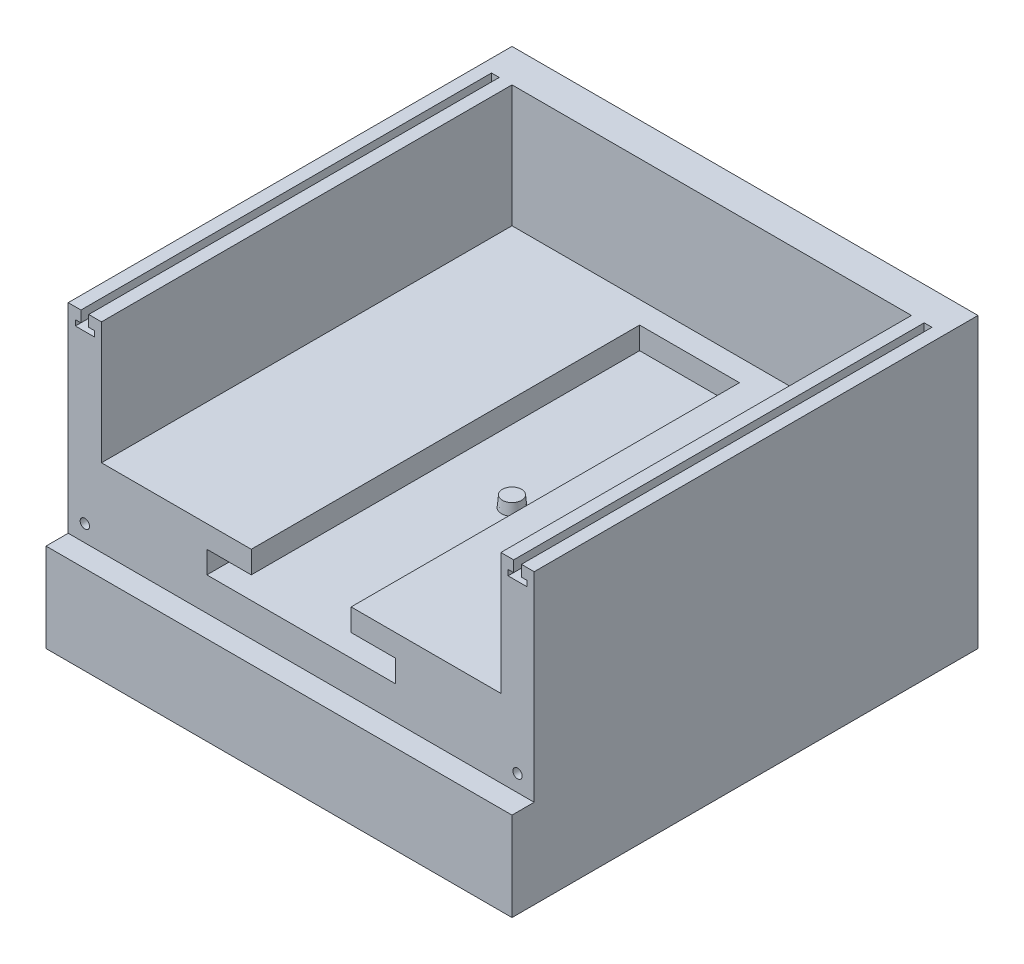
from build123d import *

# Parameters (mm, degrees)
BOSS_EXTRUDE1_DEPTH = 225
BOSS_EXTRUDE2_DEPTH = 10
SKETCH6_W           = 210
SKETCH6_H           = 200
BOSS_EXTRUDE3_DEPTH = 15
SKETCH5_R           = 2.1
CUT_EXTRUDE1_DEPTH  = 6
SKETCH10_W          = 210
SKETCH10_H          = 200
BOSS_EXTRUDE4_DEPTH = 40
SKETCH11_R          = 4.75
BOSS_EXTRUDE5_DEPTH = 5
BOSS_EXTRUDE5_TAPER = 5
SKETCH13_W          = 185
SKETCH13_H          = 10
BOSS_EXTRUDE6_DEPTH = 47.5
SKETCH14_W          = 185
SKETCH14_H          = 10
BOSS_EXTRUDE7_DEPTH = 47.5
SKETCH7_W           = 21
SKETCH7_H           = 10.25
CUT_EXTRUDE2_DEPTH  = 15
SKETCH15_R          = 2.1
CUT_EXTRUDE4_DEPTH  = 4.5
CUT_EXTRUDE5_DEPTH  = 185
SKETCH17_W          = 210
SKETCH17_H          = 40
BOSS_EXTRUDE8_DEPTH = 10


with BuildPart() as part:
    # Sketch2 → Boss-Extrude1 (new body)
    with BuildSketch(Plane(origin=(0, 0, 0), x_dir=(1, 0, 0), z_dir=(0, 1, 0))):
        Polygon((-90, 0), (90, 0), (90, -185), (105, -185), (105, 15), (-105, 15), (-105, -185), (-90, -185), align=None)
    extrude(amount=BOSS_EXTRUDE1_DEPTH)

    # Sketch3 → Boss-Extrude2 (add)
    with BuildSketch(Plane(origin=(0, 10, 0), x_dir=(1, 0, 0), z_dir=(0, 1, 0))):
        Polygon((-90, -185), (-22.5, -185), (-22.5, -10), (22.5, -10), (22.5, -185), (90, -185), (90, 0), (-90, 0), align=None)
    extrude(amount=BOSS_EXTRUDE2_DEPTH)

    # Sketch6 → Boss-Extrude3 (add)
    with BuildSketch(Plane.XZ):
        with Locations((0, 85)):
            Rectangle(SKETCH6_W, SKETCH6_H)
    extrude(amount=BOSS_EXTRUDE3_DEPTH)

    # Sketch5 → Cut-Extrude1 (cut)
    with BuildSketch(Plane.XY.offset(185)):
        with Locations((-97.5, 217.5)):
            Circle(SKETCH5_R)
        with Locations((97.5, 217.5)):
            Circle(SKETCH5_R)
        with Locations((-97.5, -7.5)):
            Circle(SKETCH5_R)
        with Locations((97.5, -7.5)):
            Circle(SKETCH5_R)
    extrude(amount=-CUT_EXTRUDE1_DEPTH, mode=Mode.SUBTRACT)

    # Sketch10 → Boss-Extrude4 (add)
    with BuildSketch(Plane.XZ.offset(15)):
        with Locations((0, 85)):
            Rectangle(SKETCH10_W, SKETCH10_H)
    extrude(amount=BOSS_EXTRUDE4_DEPTH)

    # Sketch11 → Boss-Extrude5 (add)
    with BuildSketch(Plane(origin=(0, 0, 0), x_dir=(1, 0, 0), z_dir=(0, 1, 0))):
        with Locations((0, -90)):
            Circle(SKETCH11_R)
    extrude(amount=BOSS_EXTRUDE5_DEPTH, taper=BOSS_EXTRUDE5_TAPER)

    # Sketch13 → Boss-Extrude6 (add)
    with BuildSketch(Plane.ZY.offset(-90)):
        with Locations((92.5, 5)):
            Rectangle(SKETCH13_W, SKETCH13_H)
    extrude(amount=BOSS_EXTRUDE6_DEPTH)

    # Sketch14 → Boss-Extrude7 (add)
    with BuildSketch(Plane(origin=(-90, 0, 0), x_dir=(0, 0, -1), z_dir=(1, 0, 0))):
        with Locations((-92.5, 5)):
            Rectangle(SKETCH14_W, SKETCH14_H)
    extrude(amount=BOSS_EXTRUDE7_DEPTH)

    # Sketch7 → Cut-Extrude2 (cut)
    with BuildSketch(Plane(origin=(0, 0, -15), x_dir=(-1, 0, 0), z_dir=(0, 0, -1))):
        with Locations((-32, 5.125)):
            Rectangle(SKETCH7_W, SKETCH7_H)
    extrude(amount=-CUT_EXTRUDE2_DEPTH, mode=Mode.SUBTRACT)

    # Sketch15 → Cut-Extrude4 (cut)
    with BuildSketch(Plane(origin=(0, 225, 0), x_dir=(1, 0, 0), z_dir=(0, 1, 0))):
        with Locations((0, 7.5)):
            Circle(SKETCH15_R)
        with Locations((-97.5, -90)):
            Circle(SKETCH15_R)
        with Locations((97.5, -90)):
            Circle(SKETCH15_R)
    extrude(amount=-CUT_EXTRUDE4_DEPTH, mode=Mode.SUBTRACT)

    # Split1
    split(bisect_by=Plane.ZX.offset(75), keep=Keep.BOTTOM)

    # Sketch16 → Cut-Extrude5 (cut)
    with BuildSketch(Plane.XY.offset(185)):
        Polygon((-99.25, 75), (-99.25, 70), (-101.75, 70), (-101.75, 67.5), (-93.25, 67.5), (-93.25, 70), (-95.75, 70), (-95.75, 75), align=None)
        Polygon((95.75, 70), (95.75, 75), (99.25, 75), (99.25, 70), (101.75, 70), (101.75, 67.5), (93.25, 67.5), (93.25, 70), align=None)
    extrude(amount=-CUT_EXTRUDE5_DEPTH, mode=Mode.SUBTRACT)

    # Sketch17 → Boss-Extrude8 (add)
    with BuildSketch(Plane.XY.offset(185)):
        with Locations((0, -35)):
            Rectangle(SKETCH17_W, SKETCH17_H)
    extrude(amount=BOSS_EXTRUDE8_DEPTH)


solid = part.part
